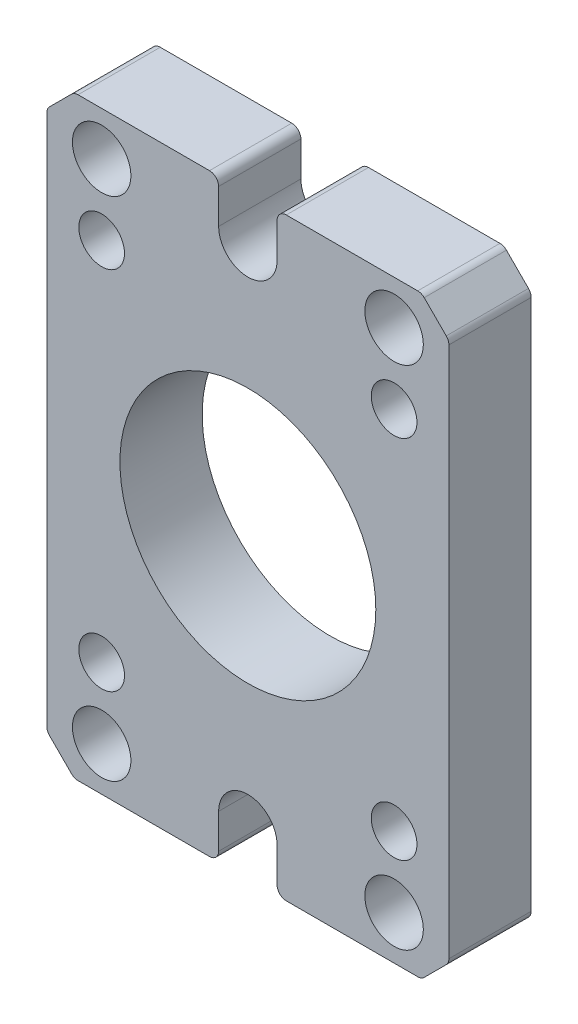
from build123d import *

# Parameters (mm, degrees)
ESBO_O1_R                = 7
ESBO_O1_R_2              = 1.6
ESBO_O1_R_3              = 1.25
RESSALTO_EXTRUS_O1_DEPTH = 4.5


with BuildPart() as part:
    # Esboço1 → Ressalto-extrusão1 (new body)
    with BuildSketch(Plane(origin=(0, 0, 0), x_dir=(-1, 0, 0), z_dir=(0, 0, -1))):
        with BuildLine():
            Line((-2.1, 16.25), (-9.292893219, 16.25))
            ThreePointArc((-9.292893219, 16.25), (-9.484234935, 16.211939766), (-9.646446609, 16.103553391))
            Line((-9.646446609, 16.103553391), (-10.853553391, 14.896446609))
            ThreePointArc((-10.853553391, 14.896446609), (-10.961939766, 14.734234935), (-11, 14.542893219))
            Line((-11, 14.542893219), (-11, -14.542893219))
            ThreePointArc((-11, -14.542893219), (-10.961939766, -14.734234935), (-10.853553391, -14.896446609))
            Line((-10.853553391, -14.896446609), (-9.646446609, -16.103553391))
            ThreePointArc((-9.646446609, -16.103553391), (-9.484234935, -16.211939766), (-9.292893219, -16.25))
            Line((-9.292893219, -16.25), (-2.1, -16.25))
            ThreePointArc((-2.1, -16.25), (-1.746446609, -16.103553391), (-1.6, -15.75))
            Line((-1.6, -15.75), (-1.6, -13.856406461))
            ThreePointArc((-1.6, -13.856406461), (0, -12.256406461), (1.6, -13.856406461))
            Line((1.6, -13.856406461), (1.6, -15.75))
            ThreePointArc((1.6, -15.75), (1.746446609, -16.103553391), (2.1, -16.25))
            Line((2.1, -16.25), (9.292893219, -16.25))
            ThreePointArc((9.292893219, -16.25), (9.484234935, -16.211939766), (9.646446609, -16.103553391))
            Line((9.646446609, -16.103553391), (10.853553391, -14.896446609))
            ThreePointArc((10.853553391, -14.896446609), (10.961939766, -14.734234935), (11, -14.542893219))
            Line((11, -14.542893219), (11, 14.542893219))
            ThreePointArc((11, 14.542893219), (10.961939766, 14.734234935), (10.853553391, 14.896446609))
            Line((10.853553391, 14.896446609), (9.646446609, 16.103553391))
            ThreePointArc((9.646446609, 16.103553391), (9.484234935, 16.211939766), (9.292893219, 16.25))
            Line((9.292893219, 16.25), (2.1, 16.25))
            ThreePointArc((2.1, 16.25), (1.746446609, 16.103553391), (1.6, 15.75))
            Line((1.6, 15.75), (1.6, 13.856406461))
            ThreePointArc((1.6, 13.856406461), (0, 12.256406461), (-1.6, 13.856406461))
            Line((-1.6, 13.856406461), (-1.6, 15.75))
            ThreePointArc((-1.6, 15.75), (-1.746446609, 16.103553391), (-2.1, 16.25))
        make_face()
        Circle(ESBO_O1_R, mode=Mode.SUBTRACT)
        with Locations((-8, -13.85640646)):
            Circle(ESBO_O1_R_2, mode=Mode.SUBTRACT)
        with Locations((8, -13.85640646)):
            Circle(ESBO_O1_R_2, mode=Mode.SUBTRACT)
        with Locations((8, 13.85640646)):
            Circle(ESBO_O1_R_2, mode=Mode.SUBTRACT)
        with Locations((-8, 13.85640646)):
            Circle(ESBO_O1_R_2, mode=Mode.SUBTRACT)
        with Locations((-8, -10)):
            Circle(ESBO_O1_R_3, mode=Mode.SUBTRACT)
        with Locations((8, -10)):
            Circle(ESBO_O1_R_3, mode=Mode.SUBTRACT)
        with Locations((8, 10)):
            Circle(ESBO_O1_R_3, mode=Mode.SUBTRACT)
        with Locations((-8, 10)):
            Circle(ESBO_O1_R_3, mode=Mode.SUBTRACT)
    extrude(amount=-RESSALTO_EXTRUS_O1_DEPTH)


solid = part.part
